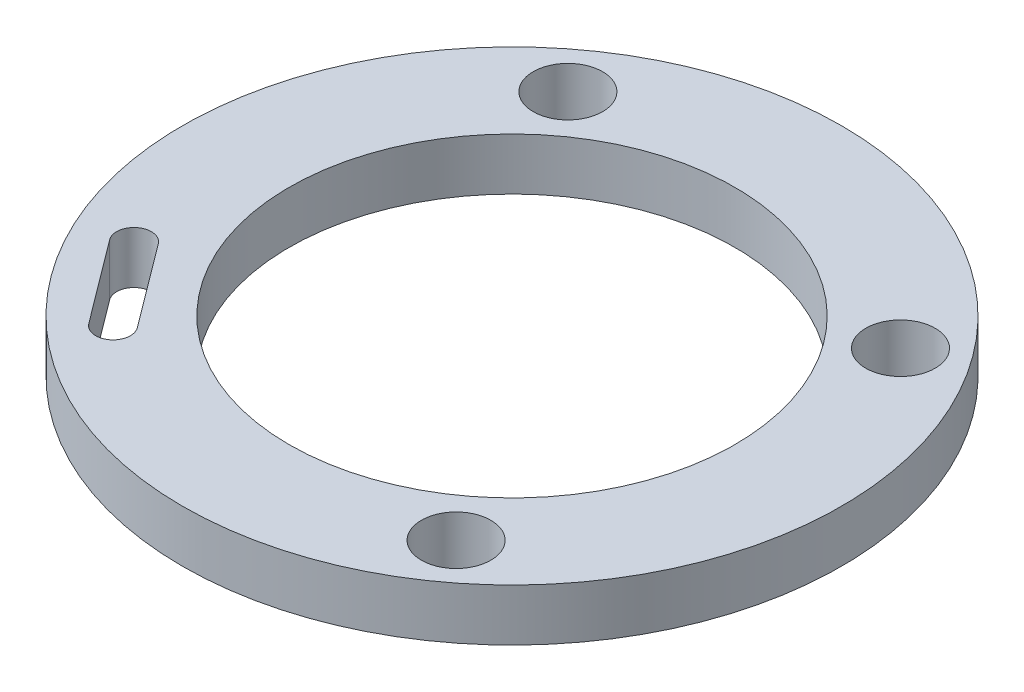
from build123d import *

# Parameters (mm, degrees)
SKETCH1_R           = 19
SKETCH1_R_2         = 12.85
SKETCH1_R_3         = 2
BOSS_EXTRUDE1_DEPTH = 3


with BuildPart() as part:
    # Sketch1 → Boss-Extrude1 (new body)
    with BuildSketch(Plane(origin=(0, 0, 0), x_dir=(1, 0, 0), z_dir=(0, 1, 0))):
        Circle(SKETCH1_R)
        Circle(SKETCH1_R_2, mode=Mode.SUBTRACT)
        with Locations((-9.586926691, 12.809794558)):
            Circle(SKETCH1_R_3, mode=Mode.SUBTRACT)
        with Locations((12.809794558, 9.586926691)):
            Circle(SKETCH1_R_3, mode=Mode.SUBTRACT)
        with Locations((9.586926691, -12.809794558)):
            Circle(SKETCH1_R_3, mode=Mode.SUBTRACT)
        with BuildLine():
            Line((-11.812857964, -12.587946089), (-15.407955473, -7.784273129))
            ThreePointArc((-15.407955473, -7.784273129), (-15.206526231, -6.384478051), (-13.806731153, -6.585907293))
            Line((-13.806731153, -6.585907293), (-10.211633644, -11.389580252))
            ThreePointArc((-10.211633644, -11.389580252), (-10.413062886, -12.78937533), (-11.812857964, -12.587946089))
        make_face(mode=Mode.SUBTRACT)
    extrude(amount=BOSS_EXTRUDE1_DEPTH)


solid = part.part
